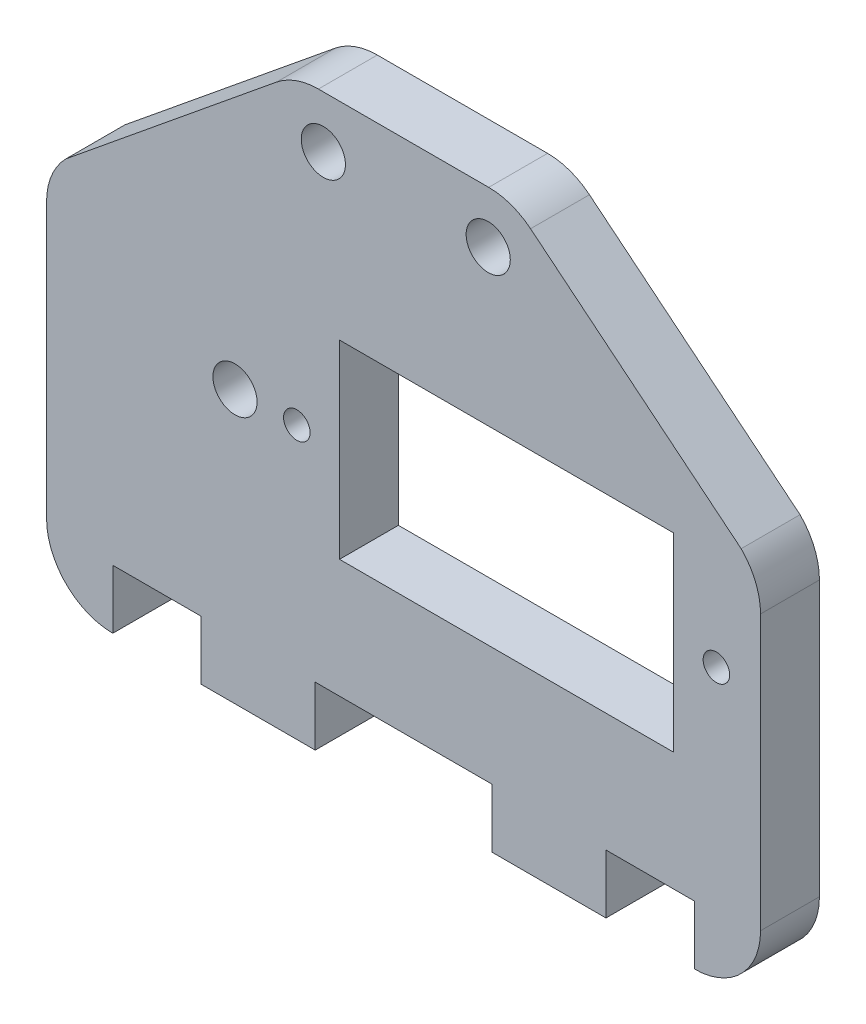
from build123d import *

# Parameters (mm, degrees)
SKETCH1_R           = 1.5
SKETCH1_R_2         = 0.9
SKETCH1_W           = 22.7
SKETCH1_H           = 12.9
BOSS_EXTRUDE1_DEPTH = 4


with BuildPart() as part:
    # Sketch1 → Boss-Extrude1 (new body)
    with BuildSketch(Plane.XY):
        with BuildLine():
            Line((48.50000085, 4.660421271), (48.50000085, 23.29646024))
            ThreePointArc((48.50000085, 23.29646024), (48.157458746, 25.018535686), (47.181981365, 26.478440755))
            Line((47.181981365, 26.478440755), (32.877904779, 38.147339677))
            ThreePointArc((32.877904779, 38.147339677), (31.543145465, 38.899591757), (30.033366148, 39.160421271))
            Line((30.033366148, 39.160421271), (18.466635551, 39.160421271))
            ThreePointArc((18.466635551, 39.160421271), (16.956856234, 38.899591757), (15.62209692, 38.147339677))
            Line((15.62209692, 38.147339677), (1.318020334, 26.478440755))
            ThreePointArc((1.318020334, 26.478440755), (0.342542953, 25.018535686), (8.5e-07, 23.29646024))
            Line((8.5e-07, 23.29646024), (8.5e-07, 4.660421271))
            ThreePointArc((8.5e-07, 4.660421271), (1.318020334, 1.478440755), (4.50000085, 0.160421271))
            Line((4.50000085, 0.160421271), (4.50000085, 4.160421271))
            Line((4.50000085, 4.160421271), (10.50000085, 4.160421271))
            Line((10.50000085, 4.160421271), (10.50000085, 0.160421271))
            Line((10.50000085, 0.160421271), (18.25000085, 0.160421271))
            Line((18.25000085, 0.160421271), (18.25000085, 4.160421271))
            Line((18.25000085, 4.160421271), (30.25000085, 4.160421271))
            Line((30.25000085, 4.160421271), (30.25000085, 0.160421271))
            Line((30.25000085, 0.160421271), (38.00000085, 0.160421271))
            Line((38.00000085, 0.160421271), (38.00000085, 4.160421271))
            Line((38.00000085, 4.160421271), (44.00000085, 4.160421271))
            Line((44.00000085, 4.160421271), (44.00000085, 0.160421271))
            ThreePointArc((44.00000085, 0.160421271), (47.181981365, 1.478440755), (48.50000085, 4.660421271))
        make_face()
        with Locations((12.80000085, 18.660421271)):
            Circle(SKETCH1_R, mode=Mode.SUBTRACT)
        with Locations((18.80000085, 35.630421271)):
            Circle(SKETCH1_R, mode=Mode.SUBTRACT)
        with Locations((30.00000085, 35.630421271)):
            Circle(SKETCH1_R, mode=Mode.SUBTRACT)
        with Locations((17.00000085, 18.660421271)):
            Circle(SKETCH1_R_2, mode=Mode.SUBTRACT)
        with Locations((45.50000085, 18.660421271)):
            Circle(SKETCH1_R_2, mode=Mode.SUBTRACT)
        with Locations((31.25000085, 18.660421271)):
            Rectangle(SKETCH1_W, SKETCH1_H, mode=Mode.SUBTRACT)
    extrude(amount=BOSS_EXTRUDE1_DEPTH)


solid = part.part
